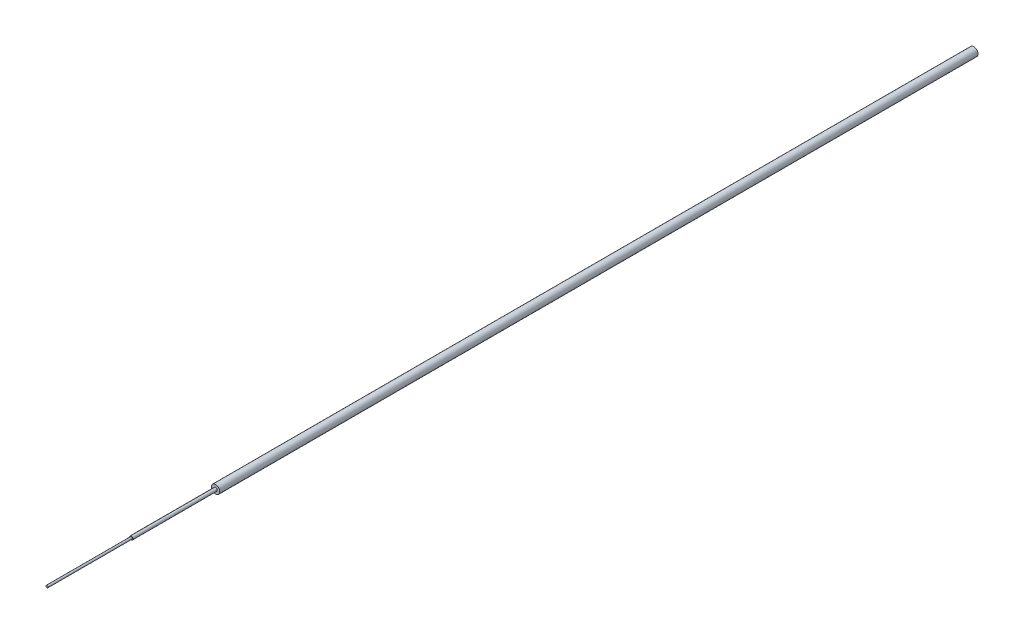
from build123d import *

# Parameters (mm, degrees)
SKETCH1_R           = 0.5
BOSS_EXTRUDE1_DEPTH = 90
SKETCH2_R           = 0.2
BOSS_EXTRUDE2_DEPTH = 10
SKETCH3_R           = 0.125
BOSS_EXTRUDE3_DEPTH = 10


with BuildPart() as part:
    # Sketch1 → Boss-Extrude1 (new body)
    with BuildSketch(Plane.XY):
        Circle(SKETCH1_R)
    extrude(amount=BOSS_EXTRUDE1_DEPTH)

    # Sketch2 → Boss-Extrude2 (add)
    with BuildSketch(Plane.XY.offset(90)):
        Circle(SKETCH2_R)
    extrude(amount=BOSS_EXTRUDE2_DEPTH)

    # Sketch3 → Boss-Extrude3 (add)
    with BuildSketch(Plane.XY.offset(100)):
        Circle(SKETCH3_R)
    extrude(amount=BOSS_EXTRUDE3_DEPTH)


solid = part.part
